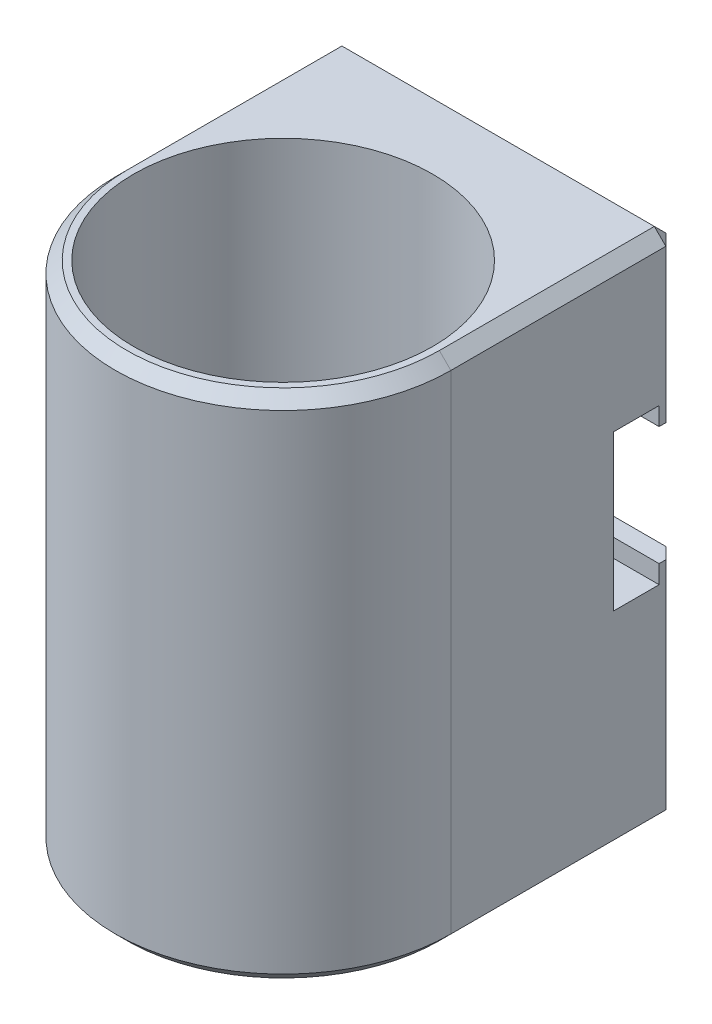
from build123d import *

# Parameters (mm, degrees)
SKETCH1_R           = 13
BOSS_EXTRUDE1_DEPTH = 44.45
CUT_EXTRUDE1_DEPTH  = 30.175
CHAMFER1_SIZE       = 1


with BuildPart() as part:
    # Sketch1 → Boss-Extrude1 (new body)
    with BuildSketch(Plane(origin=(0, 0, 0), x_dir=(1, 0, 0), z_dir=(0, 1, 0))):
        with BuildLine():
            Line((-14.5875, 0), (-14.5875, 19.7))
            Line((-14.5875, 19.7), (14.5875, 19.7))
            Line((14.5875, 19.7), (14.5875, 0))
            ThreePointArc((14.5875, 0), (0, -14.5875), (-14.5875, 0))
        make_face()
        Circle(SKETCH1_R, mode=Mode.SUBTRACT)
    extrude(amount=BOSS_EXTRUDE1_DEPTH)

    # Sketch3 → Cut-Extrude1 (cut, through all)
    with BuildSketch(Plane(origin=(14.5875, 0, 0), x_dir=(0, 0, -1), z_dir=(1, 0, 0))):
        Polygon((19.7, 30.1625), (18.1125, 30.1625), (18.1125, 31.75), (14.14375, 31.75), (14.14375, 18.25625), (18.1125, 18.25625), (18.1125, 19.84375), (19.7, 19.84375), align=None)
    extrude(amount=-CUT_EXTRUDE1_DEPTH, mode=Mode.SUBTRACT)

    # Chamfer1
    chamfer1_edges = [part.edges().sort_by_distance(p)[0] for p in [
        (0, 44.45, -19.7),
        (-14.5875, 44.45, -9.85),
        (-14.5875, 9.921875, -19.7),
        (14.5875, 9.921875, -19.7),
        (0, 44.45, 14.5875),
        (-14.5875, 0, -9.85),
        (0, 0, -19.7),
        (14.5875, 0, -9.85),
        (0, 0, 14.5875),
        (14.5875, 44.45, -9.85),
        (-14.5875, 37.30625, -19.7),
        (14.5875, 37.30625, -19.7),
    ]]
    chamfer(chamfer1_edges, length=CHAMFER1_SIZE)


solid = part.part
